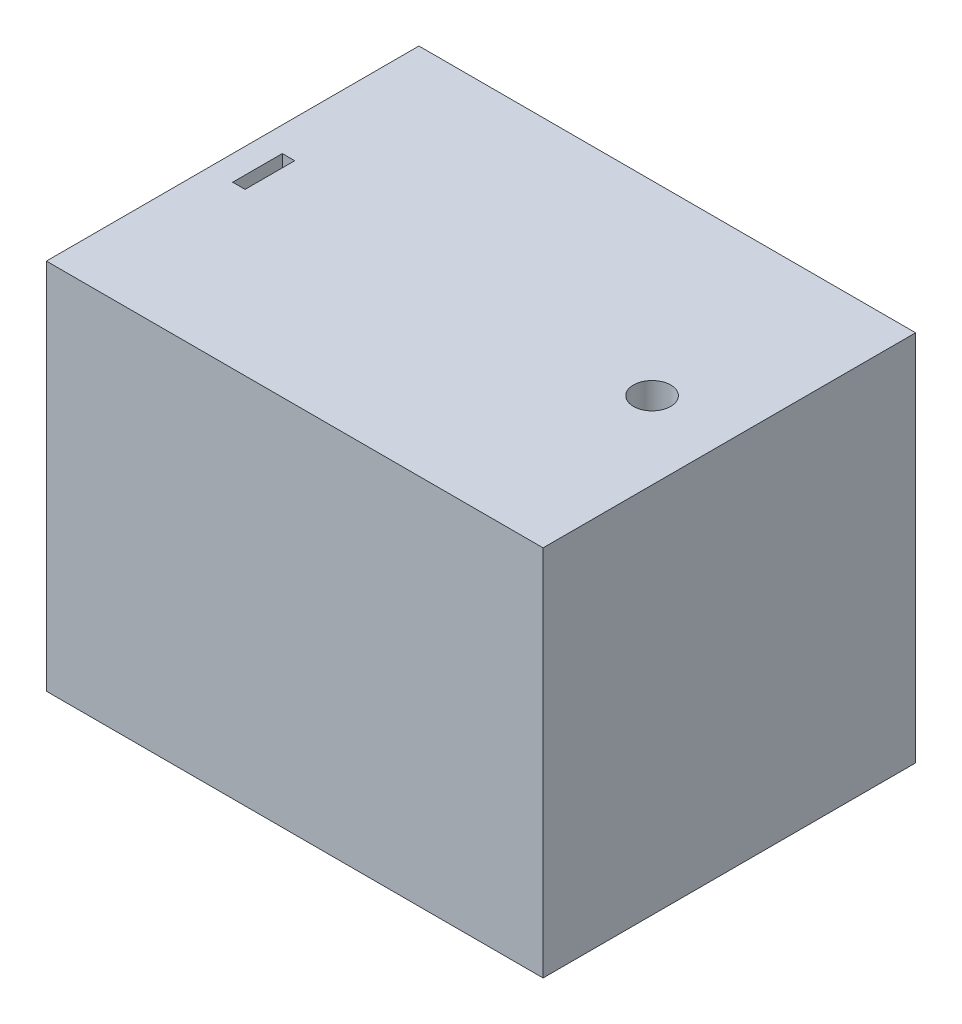
from build123d import *

# Parameters (mm, degrees)
CROQUIS1_W              = 20
CROQUIS1_H              = 15
SALIENTE_EXTRUIR1_DEPTH = 15
CROQUIS2_R              = 0.75
CORTAR_EXTRUIR1_DEPTH   = 16
CROQUIS2_3_W            = 0.5
CROQUIS2_3_H            = 2
CORTAR_EXTRUIR2_DEPTH   = 7


with BuildPart() as part:
    # Croquis1 → Saliente-Extruir1 (new body)
    with BuildSketch(Plane(origin=(0, 0, 0), x_dir=(1, 0, 0), z_dir=(0, 1, 0))):
        with Locations((10, -7.5)):
            Rectangle(CROQUIS1_W, CROQUIS1_H)
    extrude(amount=SALIENTE_EXTRUIR1_DEPTH)

    # Croquis2 → Cortar-Extruir1 (cut, through all)
    with BuildSketch(Plane(origin=(0, 15, 0), x_dir=(1, 0, 0), z_dir=(0, 1, 0))):
        with Locations(Location((16.888623538, -7.5, 0), (0, 0, 270))):  # turned: the seam where the file's is
            Circle(CROQUIS2_R)
    extrude(amount=-CORTAR_EXTRUIR1_DEPTH, mode=Mode.SUBTRACT)

    # Croquis2_3 → Cortar-Extruir2 (cut)
    with BuildSketch(Plane(origin=(0, 15, 0), x_dir=(1, 0, 0), z_dir=(0, 1, 0))):
        with Locations((1.25, -7.5)):
            Rectangle(CROQUIS2_3_W, CROQUIS2_3_H)
    extrude(amount=-CORTAR_EXTRUIR2_DEPTH, mode=Mode.SUBTRACT)


solid = part.part
